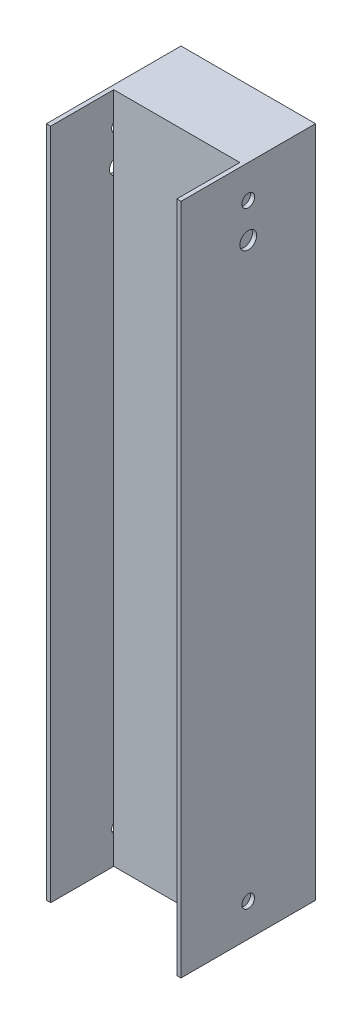
from build123d import *

# Parameters (mm, degrees)
SKETCH1_W               = 50.8
SKETCH1_H               = 50.8
SKETCH1_W_2             = 47.625
SKETCH1_H_2             = 47.625
BOSS_EXTRUDE1_DEPTH     = 254
SKETCH4_R               = 2.3999952
CUT_EXTRUDE1_DEPTH      = 50.2125
CUT_EXTRUDE1_DEPTH_BACK = 2.5875
SKETCH5_R               = 2.3999952
CUT_EXTRUDE2_DEPTH      = 51.8
SKETCH6_R               = 2.3999952
CUT_EXTRUDE3_DEPTH      = 1
CUT_EXTRUDE3_DEPTH_BACK = 51.8
SKETCH7_R               = 2.3999952
CUT_EXTRUDE4_DEPTH      = 1
CUT_EXTRUDE4_DEPTH_BACK = 51.8
SKETCH8_R               = 3.175
CUT_EXTRUDE5_DEPTH      = 1
CUT_EXTRUDE5_DEPTH_BACK = 51.8
SKETCH9_R               = 3.175
CUT_EXTRUDE6_DEPTH      = 1
CUT_EXTRUDE6_DEPTH_BACK = 51.8
CUT_EXTRUDE7_REACH      = 256
SKETCH10_W              = 47.625
SKETCH10_H              = 1.5875
SKETCH11_W              = 47.625
SKETCH11_H              = 25.4
BOSS_EXTRUDE2_DEPTH     = 254


with BuildPart() as part:
    # Sketch1 → Boss-Extrude1 (new body)
    with BuildSketch(Plane(origin=(0, 0, 0), x_dir=(1, 0, 0), z_dir=(0, 1, 0))):
        Rectangle(SKETCH1_W, SKETCH1_H)
        Rectangle(SKETCH1_W_2, SKETCH1_H_2, mode=Mode.SUBTRACT)
    extrude(amount=BOSS_EXTRUDE1_DEPTH)

    # Sketch4 → Cut-Extrude1 (cut, two sides)
    with BuildSketch(Plane(origin=(-23.8125, 0, 0), x_dir=(0, 0, -1), z_dir=(1, 0, 0))) as cut_extrude1_sk:
        with Locations((0, 241.587599882)):
            Circle(SKETCH4_R)
    extrude(amount=CUT_EXTRUDE1_DEPTH, mode=Mode.SUBTRACT)
    extrude(cut_extrude1_sk.sketch, amount=-CUT_EXTRUDE1_DEPTH_BACK, mode=Mode.SUBTRACT)

    # Sketch5 → Cut-Extrude2 (cut, through all)
    with BuildSketch(Plane(origin=(0, 0, -25.4), x_dir=(-1, 0, 0), z_dir=(0, 0, -1))):
        with Locations((0, 241.587599882)):
            Circle(SKETCH5_R)
    extrude(amount=-CUT_EXTRUDE2_DEPTH, mode=Mode.SUBTRACT)

    # Sketch6 → Cut-Extrude3 (cut, two sides)
    with BuildSketch(Plane(origin=(25.4, 0, 0), x_dir=(0, 0, -1), z_dir=(1, 0, 0))) as cut_extrude3_sk:
        with Locations((0, 12.412400118)):
            Circle(SKETCH6_R)
    extrude(amount=CUT_EXTRUDE3_DEPTH, mode=Mode.SUBTRACT)
    extrude(cut_extrude3_sk.sketch, amount=-CUT_EXTRUDE3_DEPTH_BACK, mode=Mode.SUBTRACT)

    # Sketch7 → Cut-Extrude4 (cut, two sides)
    with BuildSketch(Plane(origin=(0, 0, -25.4), x_dir=(-1, 0, 0), z_dir=(0, 0, -1))) as cut_extrude4_sk:
        with Locations((0, 12.412400118)):
            Circle(SKETCH7_R)
    extrude(amount=CUT_EXTRUDE4_DEPTH, mode=Mode.SUBTRACT)
    extrude(cut_extrude4_sk.sketch, amount=-CUT_EXTRUDE4_DEPTH_BACK, mode=Mode.SUBTRACT)

    # Sketch8 → Cut-Extrude5 (cut, two sides)
    with BuildSketch(Plane(origin=(0, 0, -25.4), x_dir=(-1, 0, 0), z_dir=(0, 0, -1))) as cut_extrude5_sk:
        with Locations((0, 228.6)):
            Circle(SKETCH8_R)
    extrude(amount=CUT_EXTRUDE5_DEPTH, mode=Mode.SUBTRACT)
    extrude(cut_extrude5_sk.sketch, amount=-CUT_EXTRUDE5_DEPTH_BACK, mode=Mode.SUBTRACT)

    # Sketch9 → Cut-Extrude6 (cut, two sides)
    with BuildSketch(Plane(origin=(25.4, 0, 0), x_dir=(0, 0, -1), z_dir=(1, 0, 0))) as cut_extrude6_sk:
        with Locations((0, 228.6)):
            Circle(SKETCH9_R)
    extrude(amount=CUT_EXTRUDE6_DEPTH, mode=Mode.SUBTRACT)
    extrude(cut_extrude6_sk.sketch, amount=-CUT_EXTRUDE6_DEPTH_BACK, mode=Mode.SUBTRACT)

    # Sketch10 → Cut-Extrude7 (cut, up to next)
    with BuildSketch(Plane.XZ, mode=Mode.PRIVATE) as cut_extrude7_sk1:
        with Locations((0, 24.60625)):
            Rectangle(SKETCH10_W, SKETCH10_H)
    cut_extrude7_tool1 = extrude(cut_extrude7_sk1.sketch, amount=-CUT_EXTRUDE7_REACH, mode=Mode.PRIVATE) & part.part
    add(cut_extrude7_tool1.solids().sort_by_distance((0, 0, 24.60625))[0], mode=Mode.SUBTRACT)

    # Sketch11 → Boss-Extrude2 (add, through all)
    with BuildSketch(Plane.XZ):
        with Locations((0, -11.1125)):
            Rectangle(SKETCH11_W, SKETCH11_H)
    extrude(amount=-BOSS_EXTRUDE2_DEPTH)


solid = part.part
